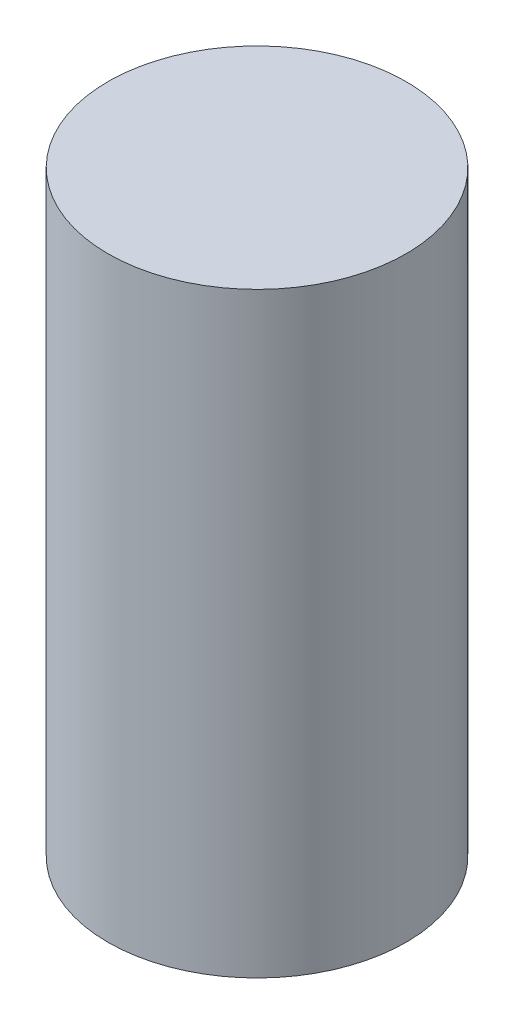
from build123d import *

# Parameters (mm, degrees)
SKETCH1_R           = 25.4
BOSS_EXTRUDE1_DEPTH = 101.6


with BuildPart() as part:
    # Sketch1 → Boss-Extrude1 (new body)
    with BuildSketch(Plane(origin=(0, 0, 0), x_dir=(1, 0, 0), z_dir=(0, 1, 0))):
        Circle(SKETCH1_R)
    extrude(amount=BOSS_EXTRUDE1_DEPTH)


solid = part.part
